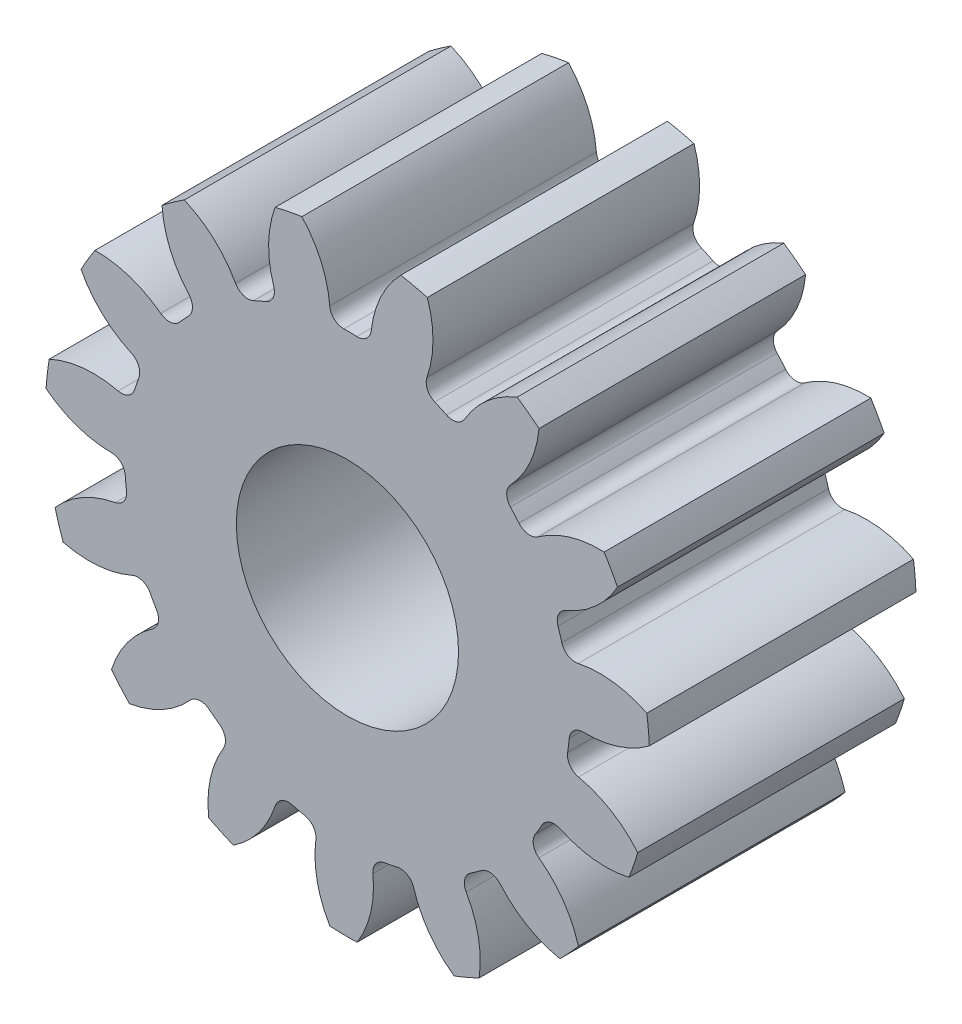
from build123d import *

# Parameters (mm, degrees)
SKETCH3_R         = 10.795
GEARBODY_DEPTH    = 9.525
TOOTHCUT_DEPTH    = 10.525
CIRPATTERN1_COUNT = 15
BOREDIA_R         = 3.96875
BORE_DEPTH        = 12700


with BuildPart() as part:
    # Sketch3 → gearBody (new body)
    with BuildSketch(Plane.XY):
        Circle(SKETCH3_R)
    extrude(amount=GEARBODY_DEPTH)

    # Sketch2 → toothCut (cut, through all)
    with BuildSketch(Plane.XY):
        with BuildLine():
            ThreePointArc((7.864672513, -1.163016041), (7.895149368, -0.933968145), (7.918956949, -0.704131297))
            ThreePointArc((7.918956949, -0.704131297), (8.083653363, -0.376064465), (8.4281848, -0.249372536))
            ThreePointArc((8.4281848, -0.249372536), (10.244786828, 0.166211992), (11.641974978, 1.399345683))
            ThreePointArc((11.641974978, 1.399345683), (11.644578548, -1.377512307), (10.99412895, -4.077116426))
            ThreePointArc((10.99412895, -4.077116426), (9.923230012, -2.552016793), (8.253736923, -1.724039588))
            ThreePointArc((8.253736923, -1.724039588), (7.948275924, -1.520455861), (7.864672513, -1.163016041))
        make_face()
    toothcut = extrude(amount=TOOTHCUT_DEPTH, mode=Mode.SUBTRACT)

    # CirPattern1: toothCut ×15 about axis
    cirpattern1_axis = Axis((0, 0, 0), (0, 0, 1))
    for i in range(1, CIRPATTERN1_COUNT):
        add(toothcut.rotate(cirpattern1_axis, i * 360 / CIRPATTERN1_COUNT), mode=Mode.SUBTRACT)

    # boreDia → bore (cut, symmetric)
    with BuildSketch(Plane.XY):
        Circle(BOREDIA_R)
    extrude(amount=BORE_DEPTH, both=True, mode=Mode.SUBTRACT)


solid = part.part
